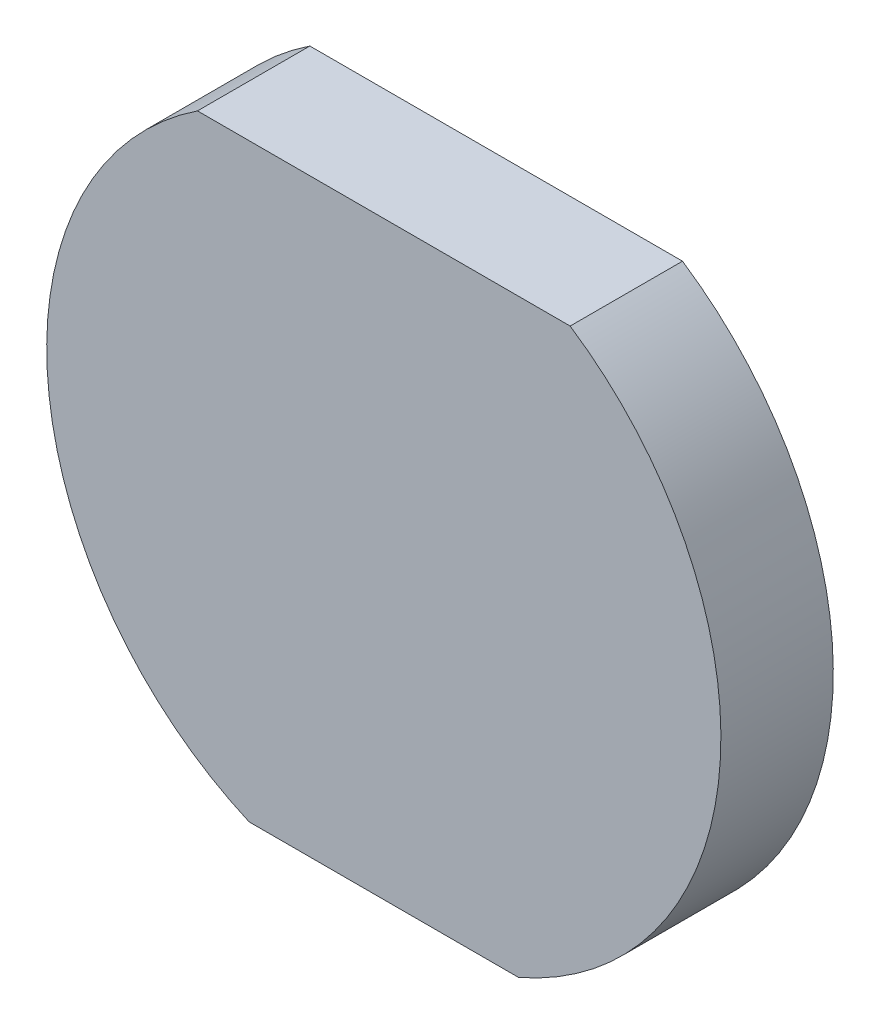
from build123d import *

# Parameters (mm, degrees)
SKETCH1_R           = 6
BOSS_EXTRUDE1_DEPTH = 2
CUT_EXTRUDE1_DEPTH  = 2


with BuildPart() as part:
    # Sketch1 → Boss-Extrude1 (new body)
    with BuildSketch(Plane.XY):
        Circle(SKETCH1_R)
    extrude(amount=BOSS_EXTRUDE1_DEPTH)

    # Sketch2 → Cut-Extrude1 (cut)
    with BuildSketch(Plane.XY.offset(2)):
        with BuildLine():
            ThreePointArc((3.31662479, 5), (0, 6), (-3.31662479, 5))
            Line((-3.31662479, 5), (3.31662479, 5))
        make_face()
        with BuildLine():
            Line((2.397915762, -5.5), (-2.397915762, -5.5))
            ThreePointArc((-2.397915762, -5.5), (0, -6), (2.397915762, -5.5))
        make_face()
    extrude(amount=-CUT_EXTRUDE1_DEPTH, mode=Mode.SUBTRACT)


solid = part.part
